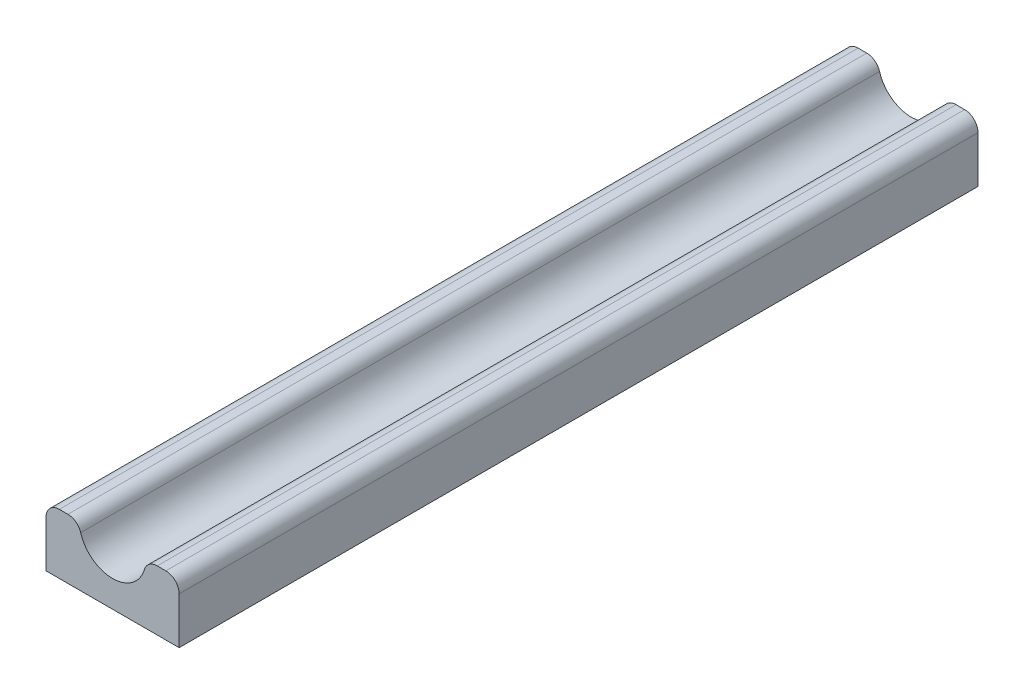
from build123d import *

# Parameters (mm, degrees)
BOSS_EXTRUDE1_DEPTH = 300


with BuildPart() as part:
    # Sketch3 → Boss-Extrude1 (new body)
    with BuildSketch(Plane.XY):
        with BuildLine():
            Line((-25, 0), (25, 0))
            Line((25, 0), (25, 17.5))
            ThreePointArc((25, 17.5), (23.535533906, 21.035533906), (20, 22.5))
            Line((20, 22.5), (16.770509831, 22.5))
            ThreePointArc((16.770509831, 22.5), (13.782438308, 21.508918629), (11.978935594, 18.928571429))
            ThreePointArc((11.978935594, 18.928571429), (0, 10), (-11.978935594, 18.928571429))
            ThreePointArc((-11.978935594, 18.928571429), (-13.782438308, 21.508918629), (-16.770509831, 22.5))
            Line((-16.770509831, 22.5), (-20, 22.5))
            ThreePointArc((-20, 22.5), (-23.535533906, 21.035533906), (-25, 17.5))
            Line((-25, 17.5), (-25, 0))
        make_face()
    extrude(amount=BOSS_EXTRUDE1_DEPTH)


solid = part.part
